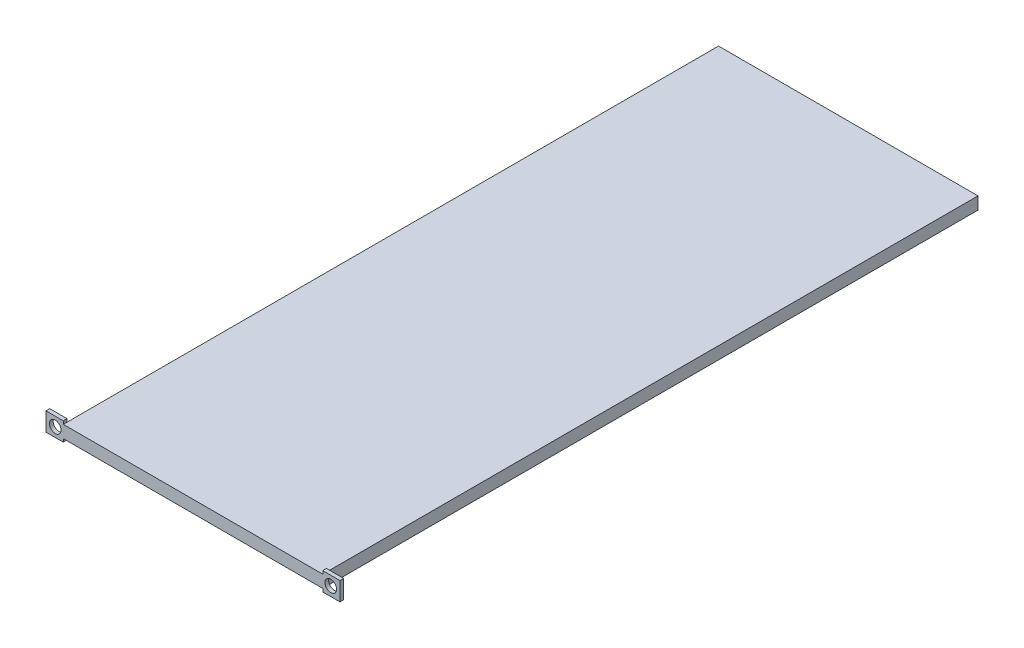
from build123d import *

# Parameters (mm, degrees)
SKETCH1_W           = 210.28
SKETCH1_H           = 10
BOSS_EXTRUDE1_DEPTH = 531
SKETCH2_W           = 3
SKETCH2_H           = 15
BOSS_EXTRUDE2_DEPTH = 14
SKETCH4_W           = 3
SKETCH4_H           = 15
BOSS_EXTRUDE3_DEPTH = 14
SKETCH3_R           = 4.7
CUT_EXTRUDE1_DEPTH  = 13


with BuildPart() as part:
    # Sketch1 → Boss-Extrude1 (new body)
    with BuildSketch(Plane.XY):
        with Locations((105.14, 5)):
            Rectangle(SKETCH1_W, SKETCH1_H)
    extrude(amount=BOSS_EXTRUDE1_DEPTH)

    # Sketch2 → Boss-Extrude2 (add)
    with BuildSketch(Plane.ZY):
        with Locations((529.5, 5)):
            Rectangle(SKETCH2_W, SKETCH2_H)
    extrude(amount=BOSS_EXTRUDE2_DEPTH)

    # Sketch4 → Boss-Extrude3 (add)
    with BuildSketch(Plane(origin=(210.28, 0, 0), x_dir=(0, 0, -1), z_dir=(1, 0, 0))):
        with Locations((-529.5, 5)):
            Rectangle(SKETCH4_W, SKETCH4_H)
    extrude(amount=BOSS_EXTRUDE3_DEPTH)

    # Sketch3 → Cut-Extrude1 (cut)
    with BuildSketch(Plane(origin=(0, 0, 528), x_dir=(-1, 0, 0), z_dir=(0, 0, -1))):
        with Locations((6.5, 5)):
            Circle(SKETCH3_R)
        with Locations((-216.78, 5)):
            Circle(SKETCH3_R)
    extrude(amount=-CUT_EXTRUDE1_DEPTH, mode=Mode.SUBTRACT)


solid = part.part
